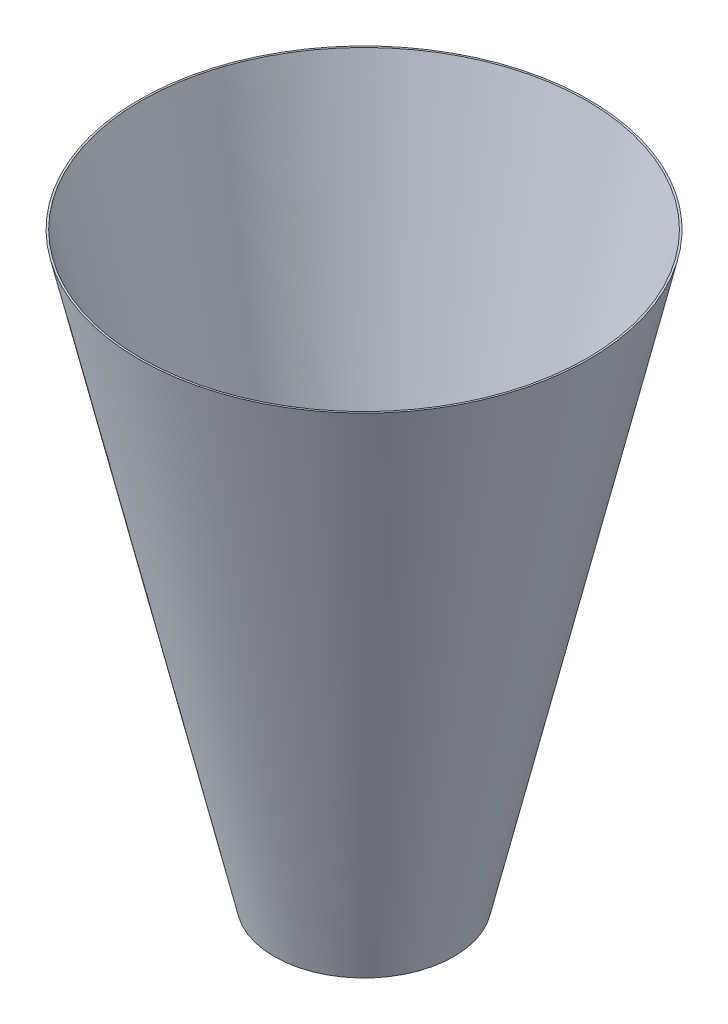
from build123d import *


with BuildPart() as part:
    # Sketch1 → Revolve1 (revolve)
    with BuildSketch(Plane.XY):
        Polygon((-100, -650), (-250, 0), (-247.947436298, 0), (-97.947436298, -650), align=None)
    revolve(axis=Axis((0, 265.385626377, 0), (0, -1, 0)))


solid = part.part
